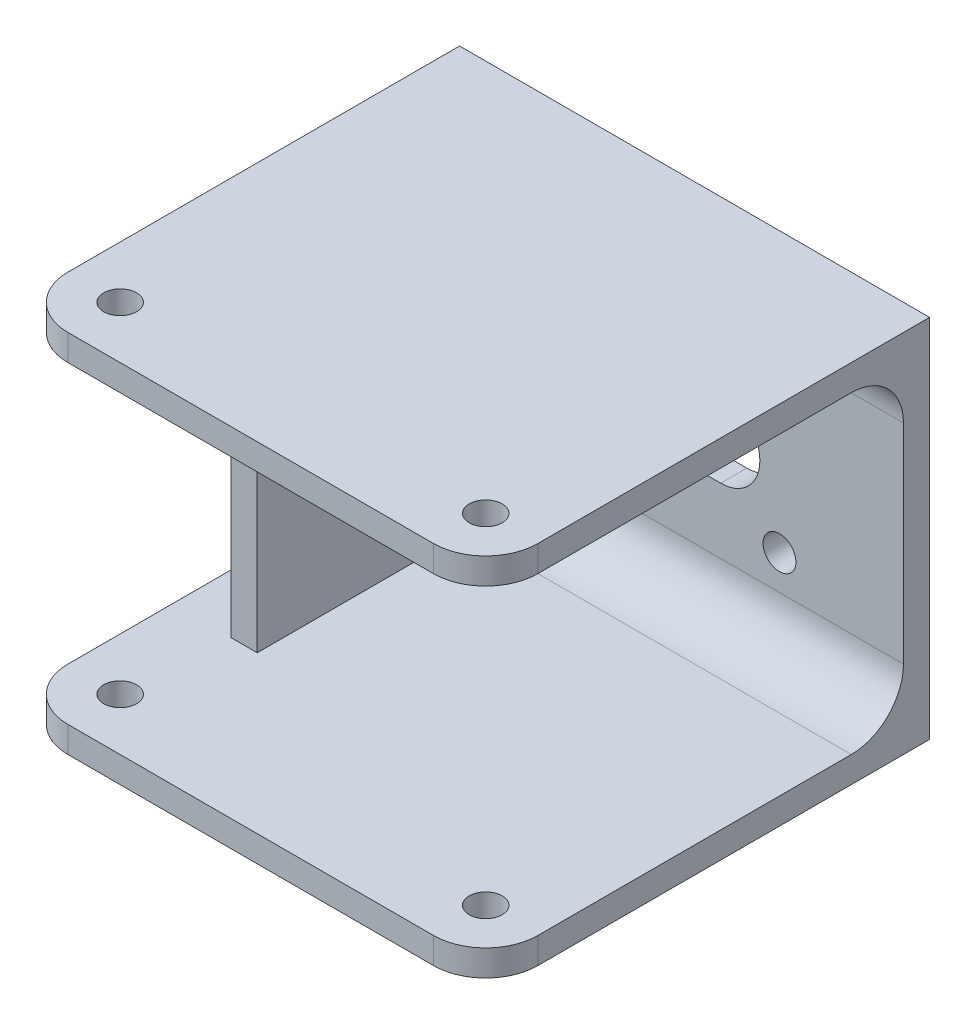
from build123d import *

# Parameters (mm, degrees)
SKETCH1_W            = 57.15
SKETCH1_H            = 38.1
BOSS_EXTRUDE1_DEPTH  = 3.175
SKETCH2_R            = 2
CUT_EXTRUDE1_DEPTH   = 35.48932806
BOSS_EXTRUDE2_START  = -3.175
SKETCH3_W            = 57.15
SKETCH3_H            = 3.175
BOSS_EXTRUDE2_DEPTH  = 53.975
CUT_EXTRUDE2_REACH   = 73.982
SKETCH5_R            = 2
FILLET1_R            = 6.35
FILLET1_OF_MIRROR1_R = 6.35
RIB1_REACH           = 77.839
SKETCH7_WALL_W       = 191.77895835
SKETCH7_WALL_H       = 3.175


with BuildPart() as part:
    # Sketch1 → Boss-Extrude1 (new body)
    with BuildSketch(Plane.XY):
        Rectangle(SKETCH1_W, SKETCH1_H)
    extrude(amount=BOSS_EXTRUDE1_DEPTH)

    # Sketch2 → Cut-Extrude1 (cut, through all)
    with BuildSketch(Plane.XY.offset(3.175)):
        with Locations((-13.5, 8.5)):
            Circle(SKETCH2_R)
        with Locations((13.5, 8.5)):
            Circle(SKETCH2_R)
        with Locations((13.5, -8.5)):
            Circle(SKETCH2_R)
        with Locations((-13.5, -8.5)):
            Circle(SKETCH2_R)
        with BuildLine():
            Line((-6.35, 4.7625), (6.35, 4.7625))
            ThreePointArc((6.35, 4.7625), (11.1125, 0), (6.35, -4.7625))
            Line((6.35, -4.7625), (-6.35, -4.7625))
            ThreePointArc((-6.35, -4.7625), (-11.1125, 0), (-6.35, 4.7625))
        make_face()
    extrude(amount=-CUT_EXTRUDE1_DEPTH, mode=Mode.SUBTRACT)

    # Sketch3 → Boss-Extrude2 (add)
    with BuildSketch(Plane.XY.offset(3.175).offset(BOSS_EXTRUDE2_START)):
        with Locations((0, 20.6375)):
            Rectangle(SKETCH3_W, SKETCH3_H)
    boss_extrude2 = extrude(amount=BOSS_EXTRUDE2_DEPTH)

    # Sketch5 → Cut-Extrude2 (cut, up to next)
    with BuildSketch(Plane.XZ.offset(-19.05), mode=Mode.PRIVATE) as cut_extrude2_sk1:
        with Locations((-22.225, 47.625)):
            Circle(SKETCH5_R)
    cut_extrude2_tool1 = extrude(cut_extrude2_sk1.sketch, amount=-CUT_EXTRUDE2_REACH, mode=Mode.PRIVATE) & part.part
    # Sketch5 → Cut-Extrude2 (cut, up to next)
    with BuildSketch(Plane.XZ.offset(-19.05), mode=Mode.PRIVATE) as cut_extrude2_sk2:
        with Locations((22.225, 47.625)):
            Circle(SKETCH5_R)
    cut_extrude2_tool2 = extrude(cut_extrude2_sk2.sketch, amount=-CUT_EXTRUDE2_REACH, mode=Mode.PRIVATE) & part.part
    cut_extrude2_1 = cut_extrude2_tool1.solids().sort_by_distance((-22.225, 19.05, 47.625))[0]
    add(cut_extrude2_1, mode=Mode.SUBTRACT)
    cut_extrude2_2 = cut_extrude2_tool2.solids().sort_by_distance((22.225, 19.05, 47.625))[0]
    add(cut_extrude2_2, mode=Mode.SUBTRACT)
    cut_extrude2 = cut_extrude2_1 + cut_extrude2_2  # Cut-Extrude2 as one shape, for the pattern or mirror that repeats it

    # Fillet1
    fillet1_edges = [part.edges().sort_by_distance(p)[0] for p in [
        (28.575, 20.6375, 53.975),
        (-28.575, 20.6375, 53.975),
        (0, 19.05, 3.175),
    ]]
    fillet(fillet1_edges, radius=FILLET1_R)

    # Mirror1: Boss-Extrude2, Cut-Extrude2 across plane
    add(boss_extrude2.mirror(Plane.ZX))
    add(cut_extrude2.mirror(Plane.ZX), mode=Mode.SUBTRACT)

    # Fillet1 of Mirror1
    fillet1_of_mirror1_edges = [part.edges().sort_by_distance(p)[0] for p in [
        (28.575, -20.6375, 53.975),
        (-28.575, -20.6375, 53.975),
        (0, -19.05, 3.175),
    ]]
    fillet(fillet1_of_mirror1_edges, radius=FILLET1_OF_MIRROR1_R)

    # Sketch7 wall → Rib1 (add, up to next)
    with BuildSketch(Plane(origin=(-19.84375, 0, 34.925), x_dir=(0, -1, 0), z_dir=(0, 0, 1)), mode=Mode.PRIVATE) as rib1_sk1:
        Rectangle(SKETCH7_WALL_W, SKETCH7_WALL_H)
    rib1_tool1 = extrude(rib1_sk1.sketch, amount=-RIB1_REACH, mode=Mode.PRIVATE) - part.part
    add(rib1_tool1.solids().sort_by_distance((-19.84375, 0, 34.925))[0])


solid = part.part
